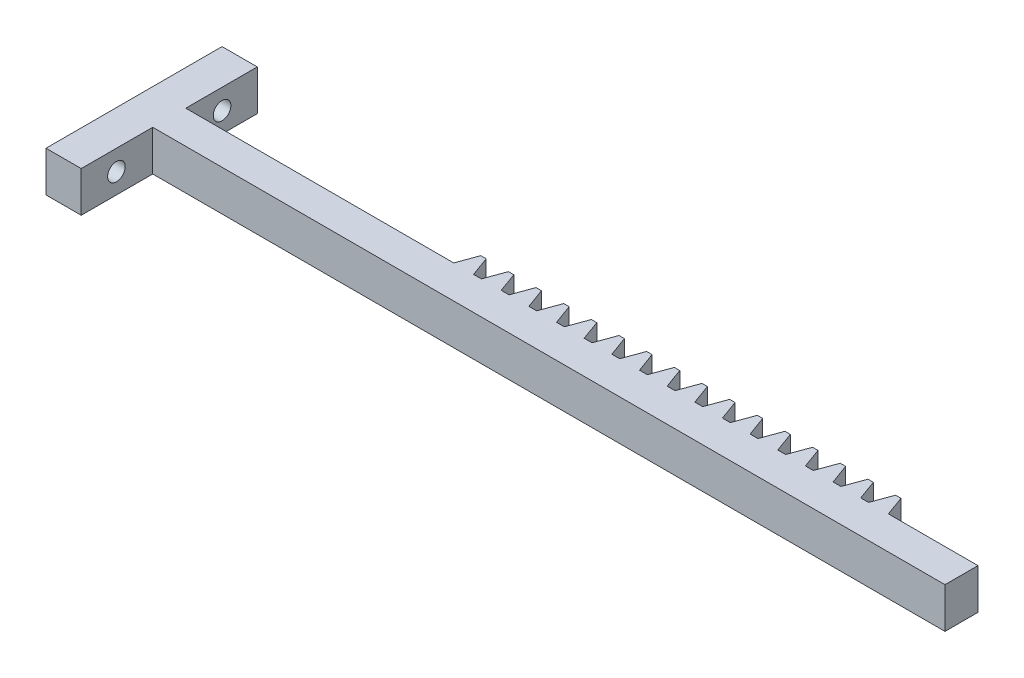
from build123d import *

# Parameters (mm, degrees)
BOSS_EXTRUDE1_DEPTH  = 4.6
SKETCH11_W           = 3.75
SKETCH11_H           = 4.6
BOSS_EXTRUDE14_DEPTH = 30
SKETCH18_W           = 20
SKETCH18_H           = 4.6
SKETCH18_R           = 1
BOSS_EXTRUDE15_DEPTH = 4
SKETCH19_W           = 3.75
SKETCH19_H           = 4.6
BOSS_EXTRUDE16_DEPTH = 10


with BuildPart() as part:
    # Sketch1 → Boss-Extrude1 (new body)
    with BuildSketch(Plane(origin=(0, 0, 0), x_dir=(1, 0, 0), z_dir=(0, 1, 0))):
        Polygon((27.324900936, 2.700375145), (27.145947966, 2.700375145), (26.327014939, 4.950375145), (25.712159083, 4.950375145), (24.893226056, 2.700375145), (24.004355316, 2.700375145), (23.185422289, 4.950375145), (22.570566433, 4.950375145), (21.751633406, 2.700375145), (20.862762666, 2.700375145), (20.043829639, 4.950375145), (19.428973783, 4.950375145), (18.610040756, 2.700375145), (17.721170016, 2.700375145), (16.902236989, 4.950375145), (16.287381133, 4.950375145), (15.468448106, 2.700375145), (14.579577366, 2.700375145), (13.760644339, 4.950375145), (13.145788483, 4.950375145), (12.326855456, 2.700375145), (11.437984716, 2.700375145), (10.619051689, 4.950375145), (10.004195833, 4.950375145), (9.185262806, 2.700375145), (8.296392066, 2.700375145), (7.477459039, 4.950375145), (6.862603183, 4.950375145), (6.043670156, 2.700375145), (5.154799416, 2.700375145), (4.335866389, 4.950375145), (3.721010533, 4.950375145), (2.902077506, 2.700375145), (2.013206766, 2.700375145), (1.194273739, 4.950375145), (0.579417883, 4.950375145), (-0.239515144, 2.700375145), (-1.128385884, 2.700375145), (-1.947318911, 4.950375145), (-2.562174767, 4.950375145), (-3.381107794, 2.700375145), (-4.269978534, 2.700375145), (-5.088911561, 4.950375145), (-5.703767417, 4.950375145), (-6.522700444, 2.700375145), (-7.411571184, 2.700375145), (-8.230504211, 4.950375145), (-8.845360067, 4.950375145), (-9.664293094, 2.700375145), (-10.553163834, 2.700375145), (-11.372096861, 4.950375145), (-11.986952717, 4.950375145), (-12.805885744, 2.700375145), (-13.694756484, 2.700375145), (-14.513689511, 4.950375145), (-15.128545367, 4.950375145), (-15.947478394, 2.700375145), (-16.836349134, 2.700375145), (-17.655282161, 4.950375145), (-18.270138017, 4.950375145), (-19.089071044, 2.700375145), (-19.977941784, 2.700375145), (-20.796874811, 4.950375145), (-21.411730667, 4.950375145), (-22.230663694, 2.700375145), (-22.675099064, 2.700375145), (-22.675099064, -1.049624855), (27.324900936, -1.049624855), align=None)
    extrude(amount=BOSS_EXTRUDE1_DEPTH)

    # Sketch11 → Boss-Extrude14 (add)
    with BuildSketch(Plane.ZY.offset(22.675099064)):
        with Locations((-0.825375145, 2.3)):
            Rectangle(SKETCH11_W, SKETCH11_H)
    extrude(amount=BOSS_EXTRUDE14_DEPTH)

    # Sketch18 → Boss-Extrude15 (add)
    with BuildSketch(Plane.ZY.offset(52.675099064)):
        with Locations((-0.825375145, 2.3)):
            Rectangle(SKETCH18_W, SKETCH18_H)
        with Locations((5.174624855, 2.3)):
            Circle(SKETCH18_R, mode=Mode.SUBTRACT)
        with Locations((-6.825375145, 2.3)):
            Circle(SKETCH18_R, mode=Mode.SUBTRACT)
    extrude(amount=BOSS_EXTRUDE15_DEPTH)

    # Sketch19 → Boss-Extrude16 (add)
    with BuildSketch(Plane(origin=(27.324900936, 0, 0), x_dir=(0, 0, -1), z_dir=(1, 0, 0))):
        with Locations((0.825375145, 2.3)):
            Rectangle(SKETCH19_W, SKETCH19_H)
    extrude(amount=BOSS_EXTRUDE16_DEPTH)


solid = part.part
